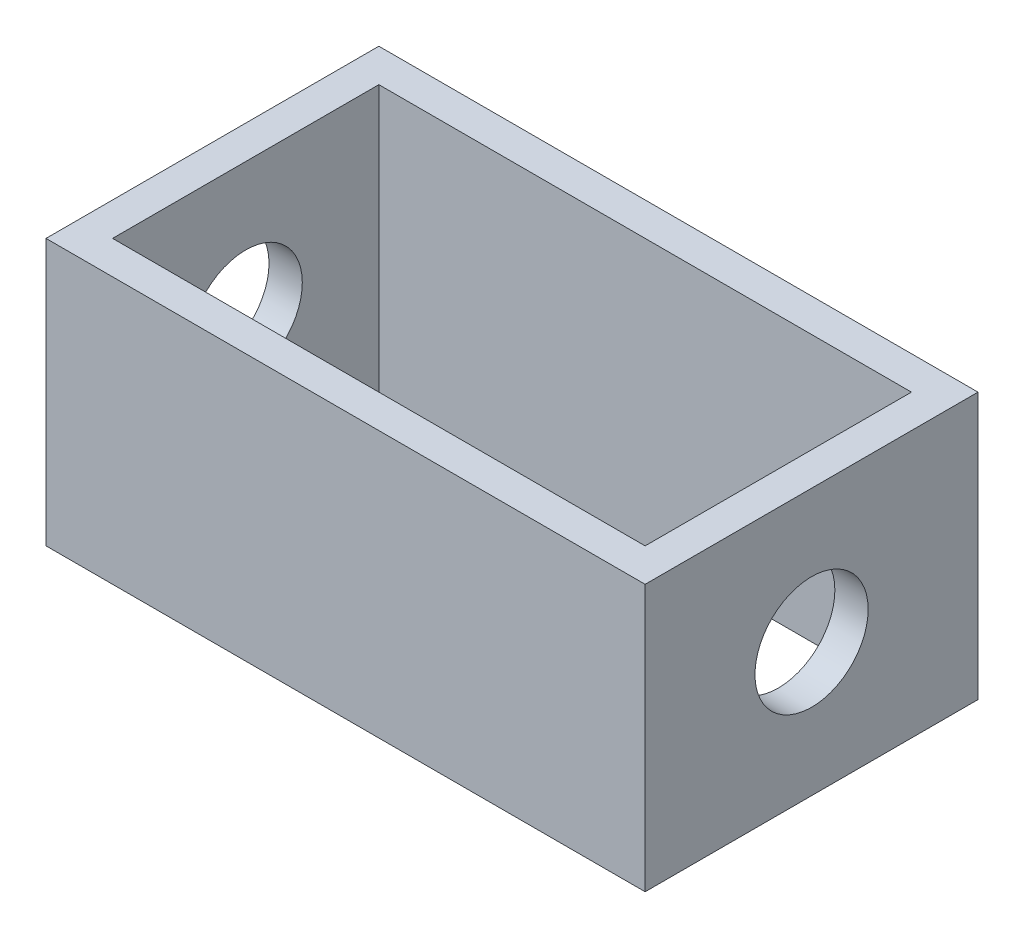
from build123d import *

# Parameters (mm, degrees)
SKETCH1_W           = 45
SKETCH1_H           = 25
SKETCH1_W_2         = 40
SKETCH1_H_2         = 20
BOSS_EXTRUDE1_DEPTH = 2.5
SKETCH2_W           = 45
SKETCH2_H           = 25
SKETCH2_W_2         = 40
SKETCH2_H_2         = 20
BOSS_EXTRUDE2_DEPTH = 17.5
SKETCH3_R           = 4.25
CUT_EXTRUDE1_DEPTH  = 46


with BuildPart() as part:
    # Sketch1 → Boss-Extrude1 (new body)
    with BuildSketch(Plane(origin=(0, 0, 0), x_dir=(1, 0, 0), z_dir=(0, 1, 0))):
        Rectangle(SKETCH1_W, SKETCH1_H)
        Rectangle(SKETCH1_W_2, SKETCH1_H_2, mode=Mode.SUBTRACT)
    extrude(amount=BOSS_EXTRUDE1_DEPTH)

    # Sketch2 → Boss-Extrude2 (add)
    with BuildSketch(Plane(origin=(0, 2.5, 0), x_dir=(1, 0, 0), z_dir=(0, 1, 0))):
        Rectangle(SKETCH2_W, SKETCH2_H)
        Rectangle(SKETCH2_W_2, SKETCH2_H_2, mode=Mode.SUBTRACT)
    extrude(amount=BOSS_EXTRUDE2_DEPTH)

    # Sketch3 → Cut-Extrude1 (cut, through all)
    with BuildSketch(Plane(origin=(22.5, 0, 0), x_dir=(0, 0, -1), z_dir=(1, 0, 0))):
        with Locations((0, 10)):
            Circle(SKETCH3_R)
    extrude(amount=-CUT_EXTRUDE1_DEPTH, mode=Mode.SUBTRACT)


solid = part.part
